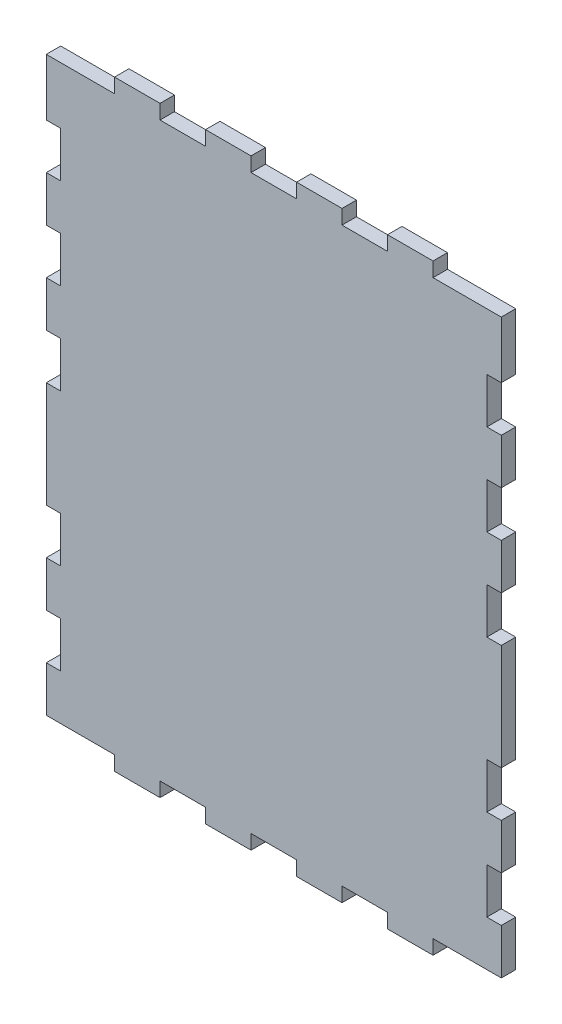
from build123d import *

# Parameters (mm, degrees)
BOSS_EXTRUDE1_DEPTH = 6.35


with BuildPart() as part:
    # Sketch1 → Boss-Extrude1 (new body)
    with BuildSketch(Plane(origin=(0, 0, -77.734937154), x_dir=(-1, 0, 0), z_dir=(0, 0, -1))):
        Polygon((0, 80), (6.35, 80), (6.35, 60), (0, 60), (0, 40), (6.35, 40), (6.35, 20), (0, 20), (0, 0), (30, 0), (30, -6.35), (50, -6.35), (50, 0), (70, 0), (70, -6.35), (90, -6.35), (90, 0), (110, 0), (110, -6.35), (130, -6.35), (130, 0), (150, 0), (150, -6.35), (170, -6.35), (170, 0), (200, 0), (200, 20), (193.65, 20), (193.65, 40), (200, 40), (200, 60), (193.65, 60), (193.65, 80), (200, 80), (200, 126.5875), (193.65, 126.5875), (193.65, 146.5875), (200, 146.5875), (200, 166.5875), (193.65, 166.5875), (193.65, 186.5875), (200, 186.5875), (200, 206.5875), (193.65, 206.5875), (193.65, 226.5875), (200, 226.5875), (200, 251.5875), (170, 251.5875), (170, 257.9375), (150, 257.9375), (150, 251.5875), (130, 251.5875), (130, 257.9375), (110, 257.9375), (110, 251.5875), (90, 251.5875), (90, 257.9375), (70, 257.9375), (70, 251.5875), (50, 251.5875), (50, 257.9375), (30, 257.9375), (30, 251.5875), (0, 251.5875), (0, 226.5875), (6.35, 226.5875), (6.35, 206.5875), (0, 206.5875), (0, 186.5875), (6.35, 186.5875), (6.35, 166.5875), (0, 166.5875), (0, 146.5875), (6.35, 146.5875), (6.35, 126.5875), (0, 126.5875), align=None)
    extrude(amount=-BOSS_EXTRUDE1_DEPTH)


solid = part.part
